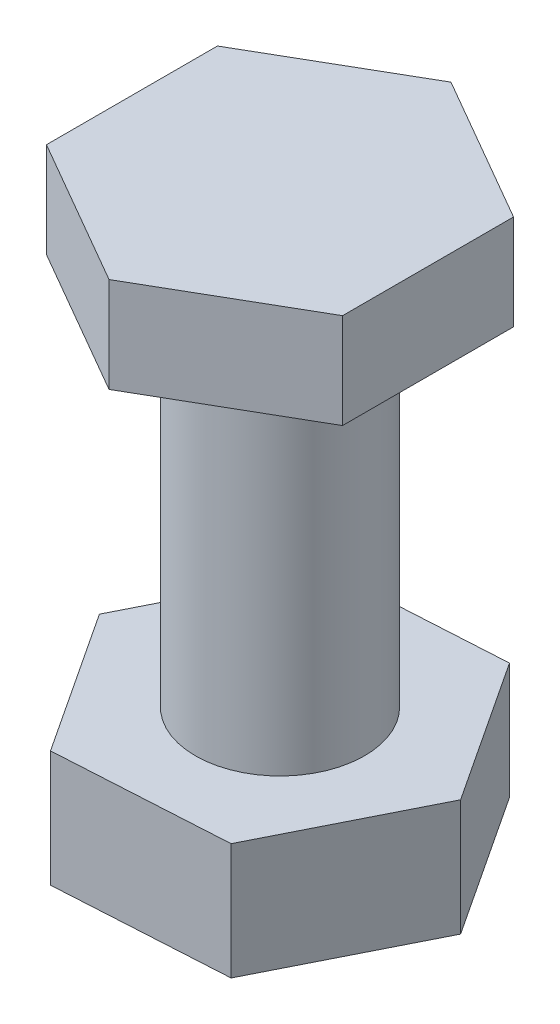
from build123d import *

# Parameters (mm, degrees)
SKETCH1_R           = 3.175
BOSS_EXTRUDE1_DEPTH = 17.1
BOSS_EXTRUDE2_DEPTH = 4.365625
BOSS_EXTRUDE3_DEPTH = 3.571875


with BuildPart() as part:
    # Sketch1 → Boss-Extrude1 (new body)
    with BuildSketch(Plane(origin=(0, 0, 0), x_dir=(1, 0, 0), z_dir=(0, 1, 0))):
        Circle(SKETCH1_R)
    extrude(amount=BOSS_EXTRUDE1_DEPTH)

    # Sketch2 → Boss-Extrude2 (add)
    with BuildSketch(Plane.XZ):
        Polygon((6.404947556, -0.373093671), (3.525582375, 5.360300458), (-2.879365181, 5.733394129), (-6.404947556, 0.373093671), (-3.525582375, -5.360300458), (2.879365181, -5.733394129), align=None)
    extrude(amount=BOSS_EXTRUDE2_DEPTH)

    # Sketch3 → Boss-Extrude3 (add)
    with BuildSketch(Plane(origin=(0, 17.1, 0), x_dir=(1, 0, 0), z_dir=(0, 1, 0))):
        Polygon((0, 6.415804866), (-5.55625, 3.207902433), (-5.55625, -3.207902433), (0, -6.415804866), (5.55625, -3.207902433), (5.55625, 3.207902433), align=None)
    extrude(amount=-BOSS_EXTRUDE3_DEPTH)


solid = part.part
